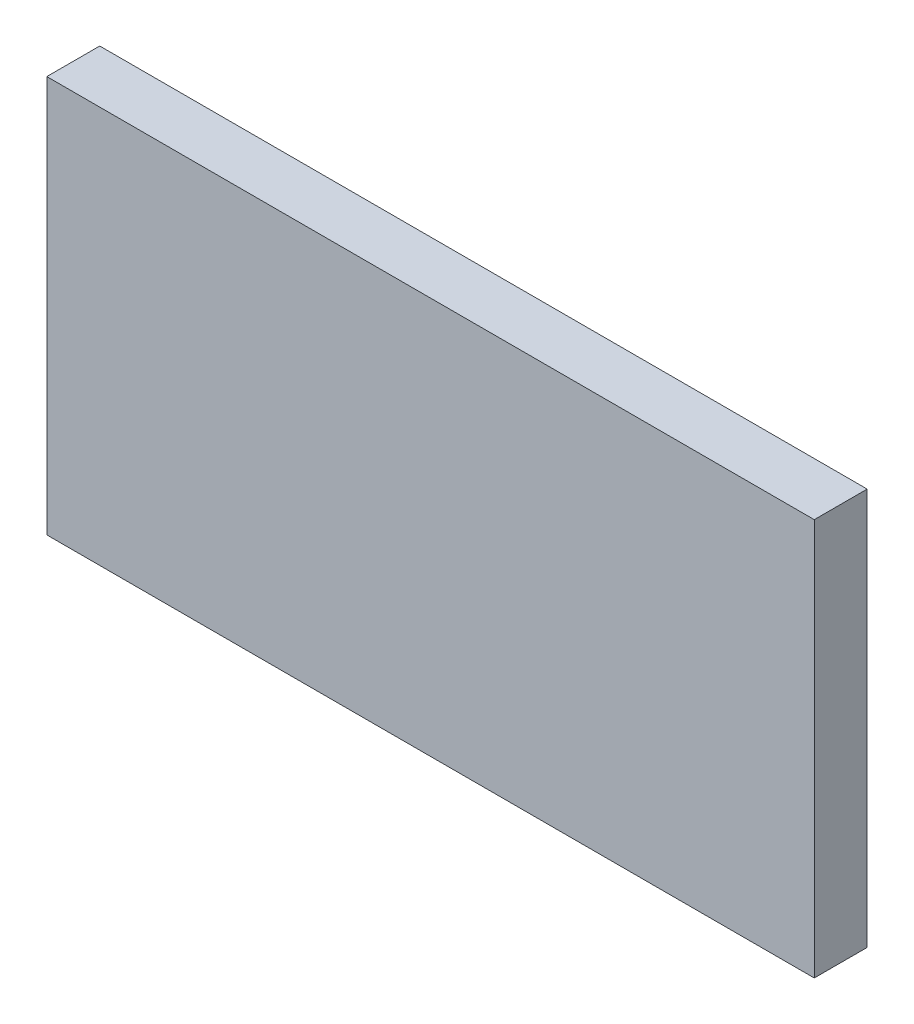
from build123d import *

# Parameters (mm, degrees)
SKETCH1_W           = 58
SKETCH1_H           = 30
BOSS_EXTRUDE1_DEPTH = 4


with BuildPart() as part:
    # Sketch1 → Boss-Extrude1 (new body)
    with BuildSketch(Plane.XY):
        with Locations((10.350514428, 8.378854626)):
            Rectangle(SKETCH1_W, SKETCH1_H)
    extrude(amount=BOSS_EXTRUDE1_DEPTH)


solid = part.part
